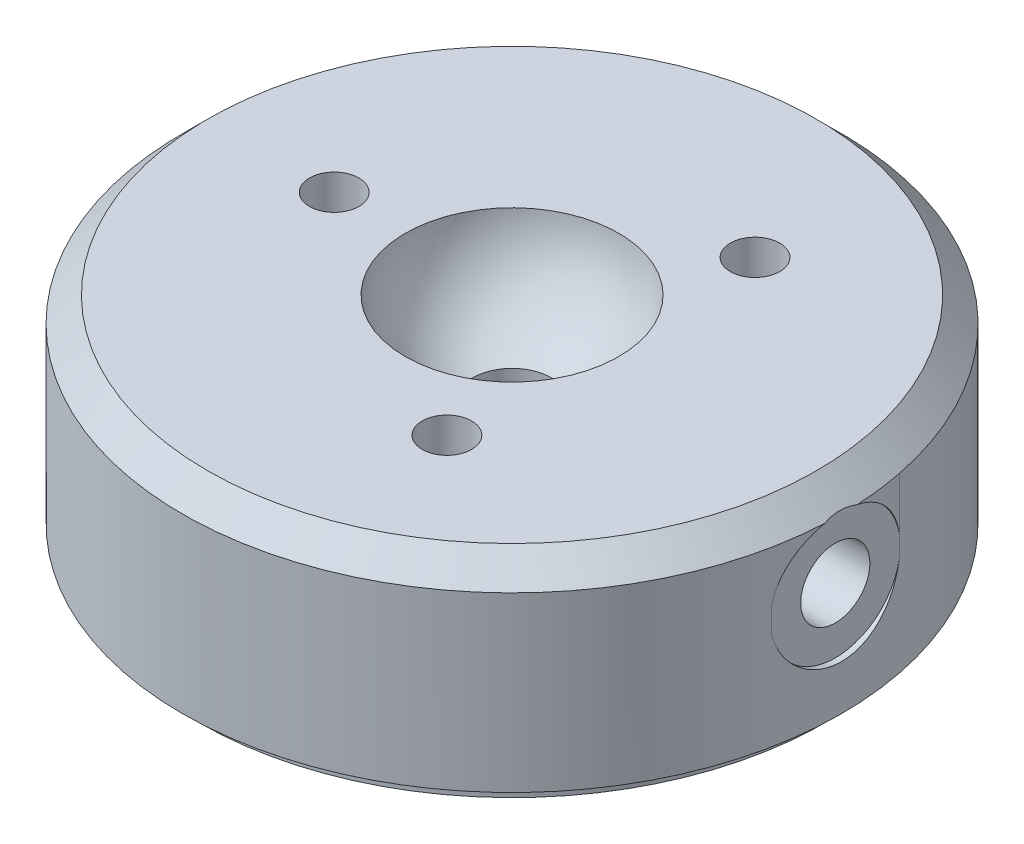
from build123d import *

# Parameters (mm, degrees)
SKETCH1_R                          = 20
EXTRUDE1_DEPTH                     = 12.0142
CHAMFER1_SIZE                      = 1.52
F_3_16_0_1875_DIAMETER_HOLE1_D     = 4.7625
F_3_16_0_1875_DIAMETER_HOLE1_DEPTH = 6.2484
SKETCH5_R                          = 18.984
EXTRUDE2_DEPTH                     = 0.98552
M5X0_8_TAPPED_HOLE1_D              = 4.2
M5X0_8_TAPPED_HOLE1_DEPTH          = 12.7
M5X0_8_TAPPED_HOLE1_TIP            = 1.2618073
CIRPATTERN1_COUNT                  = 3
SKETCH10_R                         = 3.937
CUT_EXTRUDE3_DEPTH                 = 0.381


with BuildPart() as part:
    # Sketch1 → Extrude1 (new body)
    with BuildSketch(Plane(origin=(0, 0, 0), x_dir=(1, 0, 0), z_dir=(0, 1, 0))):
        with Locations(Location((0, 0, 0), (0, 0, 270))):  # turned: the seam where the file's is
            Circle(SKETCH1_R)
    extrude(amount=EXTRUDE1_DEPTH)

    # Chamfer1
    chamfer1_edges = [part.edges().sort_by_distance(p)[0] for p in [
        (0, 12.0142, -20),
    ]]
    chamfer(chamfer1_edges, length=CHAMFER1_SIZE)

    # Sketch2 → Cut-Revolve1 (revolve, cut)
    with BuildSketch(Plane.XY):
        with BuildLine():
            Line((0, 19.0246), (0, 6.0198))
            ThreePointArc((0, 6.0198), (-6.5024, 12.5222), (0, 19.0246))
        make_face()
    revolve(axis=Axis((0, 19.0246, 0), (0, -1, 0)), mode=Mode.SUBTRACT)

    # 3_16 _0.1875_ Diameter Hole1
    with Locations(Plane(origin=(0, 12.0142, 0), x_dir=(-1, 0, 0), z_dir=(0, 1, 0))):
        with Locations((0, 0)):
            Hole(F_3_16_0_1875_DIAMETER_HOLE1_D / 2, depth=F_3_16_0_1875_DIAMETER_HOLE1_DEPTH)

    # Sketch5 → Extrude2 (add)
    with BuildSketch(Plane.XZ):
        with Locations(Location((0, 0, 0), (0, 0, 90))):  # turned: the seam where the file's is
            Circle(SKETCH5_R)
    extrude(amount=EXTRUDE2_DEPTH)

    # M5x0.8 Tapped Hole1
    with Locations(Plane(origin=(20, 6.6802, 0), x_dir=(0, 0, 1), z_dir=(1, 0, 0))):
        with Locations((0, 0)):
            Hole(M5X0_8_TAPPED_HOLE1_D / 2, depth=M5X0_8_TAPPED_HOLE1_DEPTH)
            with Locations((0, 0, -(M5X0_8_TAPPED_HOLE1_DEPTH + M5X0_8_TAPPED_HOLE1_TIP / 2))):  # 118° drill point
                Cone(0, M5X0_8_TAPPED_HOLE1_D / 2, M5X0_8_TAPPED_HOLE1_TIP, mode=Mode.SUBTRACT)

    # Sketch8 → M3x0.5 Tapped Hole1 (revolve, cut)
    with BuildSketch(Plane(origin=(-10.795, 12.0142, 0), x_dir=(0, 0, 1), z_dir=(1, 0, 0))):
        Polygon((0, 0), (0, 5.553072774), (1.25, 4.801997), (1.25, 3.302), (1.5, 3.302), (1.5, 0), align=None)
    m3x0_5_tapped_hole1 = revolve(axis=Axis((-10.795, 18.3642, 0), (0, -1, 0)), mode=Mode.SUBTRACT)

    # CirPattern1: M3x0.5 Tapped Hole1 ×3 about axis
    cirpattern1_axis = Axis((0, 0, 0), (0, 1, 0))
    for i in range(1, CIRPATTERN1_COUNT):
        add(m3x0_5_tapped_hole1.rotate(cirpattern1_axis, i * 360 / CIRPATTERN1_COUNT), mode=Mode.SUBTRACT)

    # Sketch10 → Cut-Extrude3 (cut)
    with BuildSketch(Plane(origin=(20, 5.2471, 0), x_dir=(0, 0, 1), z_dir=(1, 0, 0))):
        with Locations((0, -1.4331)):
            Circle(SKETCH10_R)
    extrude(amount=-CUT_EXTRUDE3_DEPTH, mode=Mode.SUBTRACT)


solid = part.part
